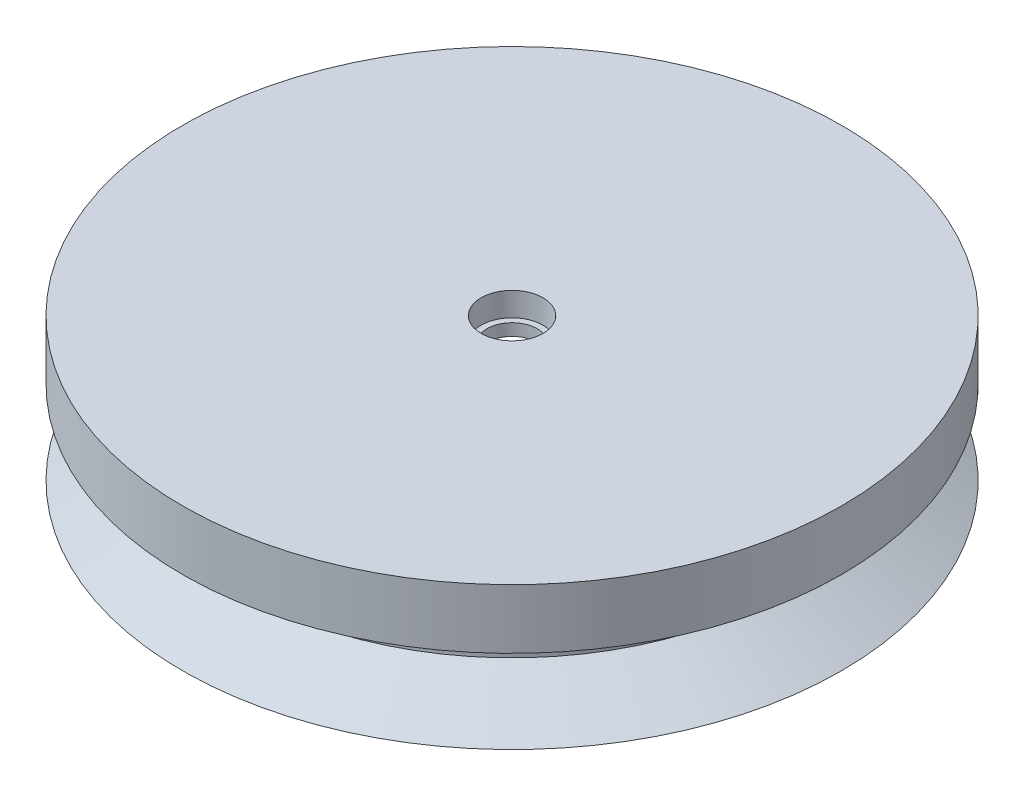
from build123d import *


with BuildPart() as part:
    # Sketch1 → Revolve1 (revolve)
    with BuildSketch(Plane.XY):
        Polygon((2.1, 1), (2.6, 1), (2.6, 3), (27.696152423, 3), (27.696152423, -2), (22.5, -5), (22.5, -6), (27.696152423, -9), (21, -9), (21, -2), (20, -2), (20, 0), (2.1, 0), align=None)
    revolve(axis=Axis((0, 0, 0), (0, 1, 0)))


solid = part.part
